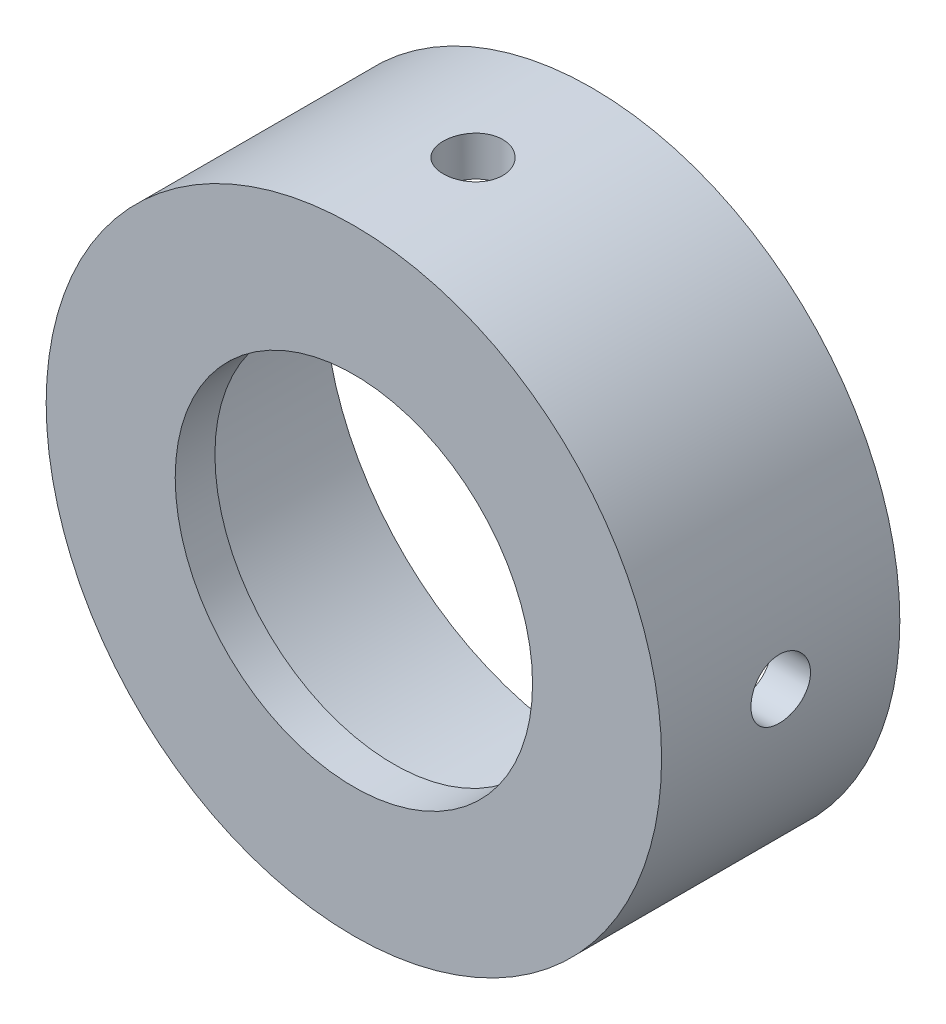
from build123d import *

# Parameters (mm, degrees)
ESQUISSE3_R                  = 1.5
ENL_V_MAT_EXTRU_1_DEPTH      = 5
R_P_TITION_CIRCULAIRE1_COUNT = 4


with BuildPart() as part:
    # Esquisse1 → Révolution1 (revolve)
    with BuildSketch(Plane(origin=(0, 0, 0), x_dir=(0, 0, -1), z_dir=(1, 0, 0))):
        Polygon((-6, 15.5), (6, 15.5), (6, 13.5), (-4, 13.5), (-4, 9), (-6, 9), align=None)
    revolve(axis=Axis((0, 0, 6), (0, 0, -1)))

    # Esquisse3 → Enlèv. mat.-Extru.1 (cut)
    with BuildSketch(Plane(origin=(0, 15.5, 0), x_dir=(1, 0, 0), z_dir=(0, 1, 0))):
        Circle(ESQUISSE3_R)
    enl_v_mat_extru_1 = extrude(amount=-ENL_V_MAT_EXTRU_1_DEPTH, mode=Mode.SUBTRACT)

    # Répétition circulaire1: Enlèv. mat.-Extru.1 ×4 about axis
    r_p_tition_circulaire1_axis = Axis((0, 0, 6), (0, 0, 1))
    for i in range(1, R_P_TITION_CIRCULAIRE1_COUNT):
        add(enl_v_mat_extru_1.rotate(r_p_tition_circulaire1_axis, i * 360 / R_P_TITION_CIRCULAIRE1_COUNT), mode=Mode.SUBTRACT)


solid = part.part
